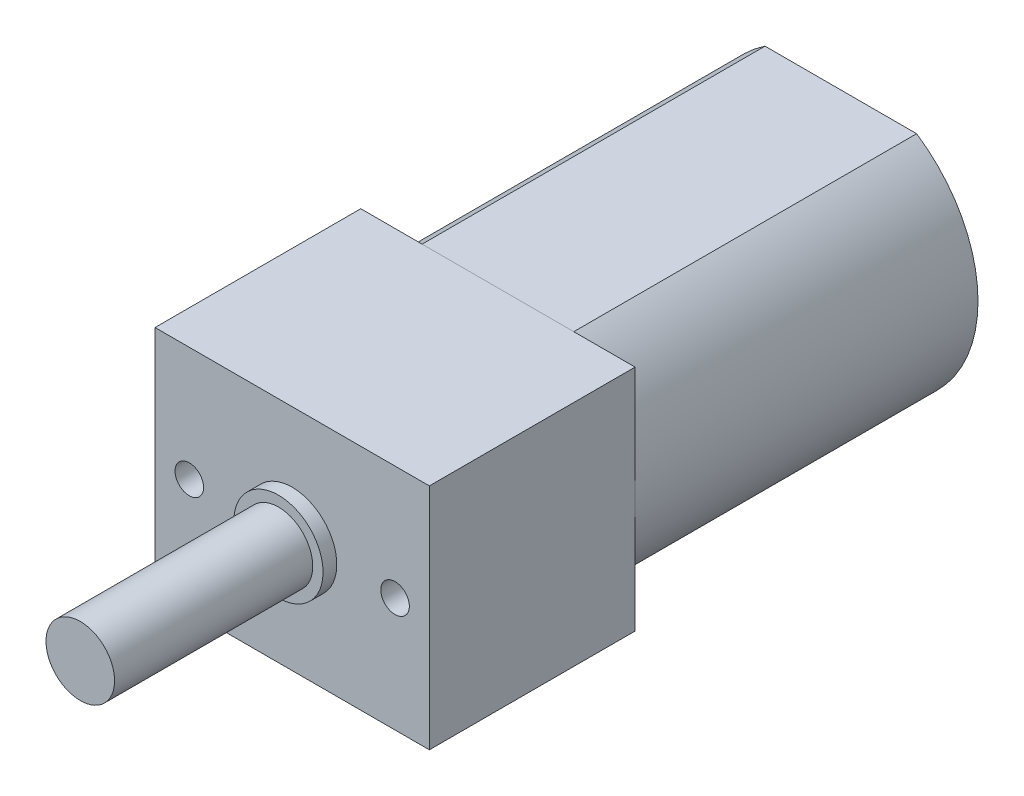
from build123d import *

# Parameters (mm, degrees)
SKETCH1_W                         = 12
SKETCH1_H                         = 10
BOSS_EXTRUDE1_DEPTH               = 9
BOSS_EXTRUDE2_DEPTH               = 15
SKETCH4_R                         = 2.5
BOSS_EXTRUDE3_DEPTH               = 2
M1_6X0_35_TAPPED_HOLE1_AT_2_COUNT = 2
M1_6X0_35_TAPPED_HOLE1_AT_2_PITCH = 9


with BuildPart() as part:
    # Sketch1 → Boss-Extrude1 (new body)
    with BuildSketch(Plane.XY):
        Rectangle(SKETCH1_W, SKETCH1_H)
    extrude(amount=BOSS_EXTRUDE1_DEPTH)

    # Sketch2 → Revolve1 (revolve)
    with BuildSketch(Plane(origin=(0, 0, 0), x_dir=(0, 0, -1), z_dir=(1, 0, 0))):
        Polygon((-9, 0), (-9, 1.95), (-9.6, 1.95), (-9.6, 1.5), (-18.27, 1.5), (-18.27, 0), align=None)
    revolve(axis=Axis((0, 0, 9), (0, 0, 1)))

    # Sketch5 → M1.6x0.35 Tapped Hole1 (revolve, cut)
    with BuildSketch(Plane(origin=(-4.5, 0, 9), x_dir=(0, -1, 0), z_dir=(1, 0, 0))):
        Polygon((0, 0), (0, 2.425537887), (0.625, 2.05), (0.625, 0), align=None)
    m1_6x0_35_tapped_hole1 = revolve(axis=Axis((-4.5, 0, 15.35), (0, 0, -1)), mode=Mode.SUBTRACT)

    # M1.6x0.35 Tapped Hole1 at 2: M1.6x0.35 Tapped Hole1 ×2
    with Locations(*[(i * M1_6X0_35_TAPPED_HOLE1_AT_2_PITCH, 0, 0) for i in range(1, M1_6X0_35_TAPPED_HOLE1_AT_2_COUNT)]):
        add(m1_6x0_35_tapped_hole1, mode=Mode.SUBTRACT)


with BuildPart() as body_2:
    # Sketch3 → Boss-Extrude2 (new body)
    with BuildSketch(Plane(origin=(0, 0, 0), x_dir=(-1, 0, 0), z_dir=(0, 0, -1))):
        with BuildLine():
            Line((-3.31662479, 5), (3.31662479, 5))
            ThreePointArc((3.31662479, 5), (6, 0), (3.31662479, -5))
            Line((3.31662479, -5), (-3.31662479, -5))
            ThreePointArc((-3.31662479, -5), (-6, 0), (-3.31662479, 5))
        make_face()
    extrude(amount=BOSS_EXTRUDE2_DEPTH)


with BuildPart() as body_3:
    # Sketch4 → Boss-Extrude3 (new body)
    with BuildSketch(Plane(origin=(0, 0, -15), x_dir=(-1, 0, 0), z_dir=(0, 0, -1))):
        Circle(SKETCH4_R)
    extrude(amount=BOSS_EXTRUDE3_DEPTH)


solid = Compound([part.part, body_2.part, body_3.part])
